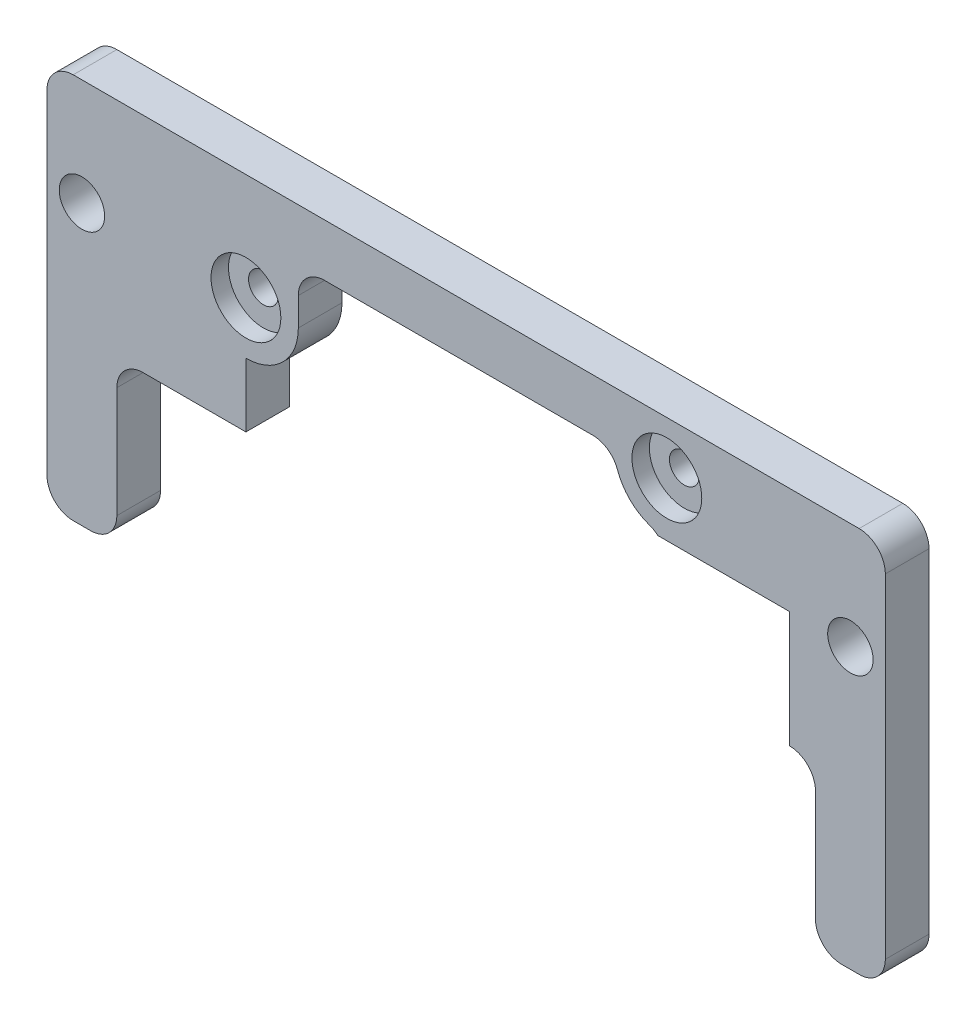
from build123d import *

# Parameters (mm, degrees)
ESQUISSE1_R             = 2.6
ESQUISSE1_R_2           = 1.7
BOSS_EXTRU_1_DEPTH      = 5
ESQUISSE2_R             = 4
ENL_V_MAT_EXTRU_1_DEPTH = 2
ENL_V_MAT_EXTRU_2_DEPTH = 5


with BuildPart() as part:
    # Esquisse1 → Boss.-Extru.1 (new body)
    with BuildSketch(Plane.XY):
        with BuildLine():
            Line((7, -13.31223453), (81, -13.31223453))
            ThreePointArc((81, -13.31223453), (83.121320344, -14.190914186), (84, -16.31223453))
            Line((84, -16.31223453), (84, -29))
            ThreePointArc((84, -29), (84.878679656, -31.121320344), (87, -32))
            Line((87, -32), (89, -32))
            ThreePointArc((89, -32), (91.121320344, -31.121320344), (92, -29))
            Line((92, -29), (92, 9.22))
            ThreePointArc((92, 9.22), (91.121320344, 11.341320344), (89, 12.22))
            Line((89, 12.22), (-1, 12.22))
            ThreePointArc((-1, 12.22), (-3.121320344, 11.341320344), (-4, 9.22))
            Line((-4, 9.22), (-4, -29))
            ThreePointArc((-4, -29), (-3.121320344, -31.121320344), (-1, -32))
            Line((-1, -32), (1, -32))
            ThreePointArc((1, -32), (3.121320344, -31.121320344), (4, -29))
            Line((4, -29), (4, -16.31223453))
            ThreePointArc((4, -16.31223453), (4.878679656, -14.190914186), (7, -13.31223453))
        make_face()
        Circle(ESQUISSE1_R, mode=Mode.SUBTRACT)
        with Locations((88, 0)):
            Circle(ESQUISSE1_R, mode=Mode.SUBTRACT)
        with Locations((18.779545265, 0)):
            Circle(ESQUISSE1_R_2, mode=Mode.SUBTRACT)
        with Locations((66.979545265, 6.22)):
            Circle(ESQUISSE1_R_2, mode=Mode.SUBTRACT)
    extrude(amount=BOSS_EXTRU_1_DEPTH)

    # Esquisse2 → Enlèv. mat.-Extru.1 (cut)
    with BuildSketch(Plane.XY.offset(5)):
        with Locations((18.779545265, 0)):
            Circle(ESQUISSE2_R)
        with Locations((66.979545265, 6.22)):
            Circle(ESQUISSE2_R)
    extrude(amount=-ENL_V_MAT_EXTRU_1_DEPTH, mode=Mode.SUBTRACT)

    # Esquisse3 → Enlèv. mat.-Extru.2 (cut)
    with BuildSketch(Plane.XY.offset(5)):
        with BuildLine():
            Line((18.779545265, -6), (18.779545265, -10.31223453))
            Line((18.779545265, -10.31223453), (18.779545265, -13.31223453))
            Line((18.779545265, -13.31223453), (21.779545265, -13.31223453))
            Line((21.779545265, -13.31223453), (63.979545265, -13.31223453))
            Line((63.979545265, -13.31223453), (81, -13.31223453))
            Line((81, -13.31223453), (81, 0))
            Line((81, 0), (65.946395614, 0))
            ThreePointArc((65.946395614, 0), (65.489457028, 0.327047013), (64.979545265, 0.563145751))
            ThreePointArc((64.979545265, 0.563145751), (62.736904578, 1.977359313), (61.322691016, 4.22))
            ThreePointArc((61.322691016, 4.22), (60.226314699, 5.669489743), (58.494263891, 6.22))
            Line((58.494263891, 6.22), (27.779545265, 6.22))
            ThreePointArc((27.779545265, 6.22), (25.658224922, 5.341320344), (24.779545265, 3.22))
            Line((24.779545265, 3.22), (24.779545265, 0))
            ThreePointArc((24.779545265, 0), (23.022185952, -4.242640687), (18.779545265, -6))
        make_face()
    extrude(amount=-ENL_V_MAT_EXTRU_2_DEPTH, mode=Mode.SUBTRACT)


solid = part.part
